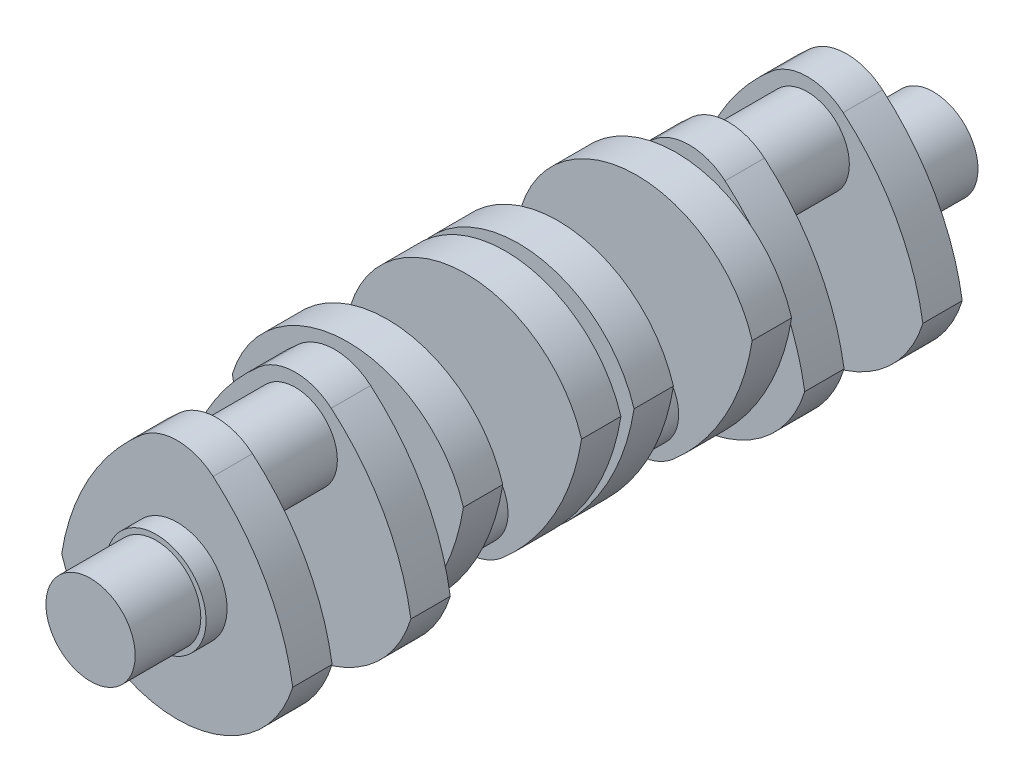
from build123d import *

# Parameters (mm, degrees)
SKETCH1_R           = 17
BOSS_EXTRUDE1_DEPTH = 25
SKETCH2_R           = 19
BOSS_EXTRUDE2_DEPTH = 8
BOSS_EXTRUDE3_DEPTH = 15
SKETCH4_R           = 16
BOSS_EXTRUDE4_DEPTH = 15
SKETCH5_R           = 17
BOSS_EXTRUDE5_DEPTH = 5
BOSS_EXTRUDE6_DEPTH = 15
SKETCH7_R           = 16
BOSS_EXTRUDE7_DEPTH = 30
BOSS_EXTRUDE8_DEPTH = 15
SKETCH9_R           = 17
BOSS_EXTRUDE9_DEPTH = 2.5


with BuildPart() as part:
    # Sketch1 → Boss-Extrude1 (new body)
    with BuildSketch(Plane.XY):
        Circle(SKETCH1_R)
    extrude(amount=BOSS_EXTRUDE1_DEPTH)

    # Sketch2 → Boss-Extrude2 (add)
    with BuildSketch(Plane(origin=(0, 0, 0), x_dir=(-1, 0, 0), z_dir=(0, 0, -1))):
        Circle(SKETCH2_R)
    extrude(amount=BOSS_EXTRUDE2_DEPTH)

    # Sketch3 → Boss-Extrude3 (add)
    with BuildSketch(Plane(origin=(0, 0, -8), x_dir=(-1, 0, 0), z_dir=(0, 0, -1))):
        with BuildLine():
            ThreePointArc((-44, -13.416407865), (0, -46), (44, -13.416407865))
            ThreePointArc((44, -13.416407865), (33.683444249, 16.469257624), (13.668094758, 40.943123461))
            ThreePointArc((13.668094758, 40.943123461), (0, 46), (-13.668094758, 40.943123461))
            ThreePointArc((-13.668094758, 40.943123461), (-33.683444249, 16.469257624), (-44, -13.416407865))
        make_face()
    boss_extrude3 = extrude(amount=BOSS_EXTRUDE3_DEPTH)

    # Sketch4 → Boss-Extrude4 (add)
    with BuildSketch(Plane(origin=(0, 0, -23), x_dir=(-1, 0, 0), z_dir=(0, 0, -1))):
        with Locations((0, 25)):
            Circle(SKETCH4_R)
    boss_extrude4 = extrude(amount=BOSS_EXTRUDE4_DEPTH)

    # Mirror2: Boss-Extrude3, Boss-Extrude4 across plane
    add(boss_extrude3.mirror(Plane(origin=(0, 25, -38), x_dir=(1, 0, 0), z_dir=(0, 0, -1))))
    add(boss_extrude4.mirror(Plane(origin=(0, 25, -38), x_dir=(1, 0, 0), z_dir=(0, 0, -1))))

    # Sketch5 → Boss-Extrude5 (add)
    with BuildSketch(Plane(origin=(0, 0, -68), x_dir=(-1, 0, 0), z_dir=(0, 0, -1))):
        Circle(SKETCH5_R)
    extrude(amount=BOSS_EXTRUDE5_DEPTH)

    # Sketch6 → Boss-Extrude6 (add)
    with BuildSketch(Plane(origin=(0, 0, -73), x_dir=(-1, 0, 0), z_dir=(0, 0, -1))):
        with BuildLine():
            ThreePointArc((44, 13.416407865), (0, 46), (-44, 13.416407865))
            ThreePointArc((-44, 13.416407865), (-33.683444249, -16.469257624), (-13.668094758, -40.943123461))
            ThreePointArc((-13.668094758, -40.943123461), (0, -46), (13.668094758, -40.943123461))
            ThreePointArc((13.668094758, -40.943123461), (33.683444249, -16.469257624), (44, 13.416407865))
        make_face()
    extrude(amount=BOSS_EXTRUDE6_DEPTH)

    # Sketch7 → Boss-Extrude7 (add)
    with BuildSketch(Plane(origin=(0, 0, -88), x_dir=(-1, 0, 0), z_dir=(0, 0, -1))):
        with Locations((0, -25)):
            Circle(SKETCH7_R)
    extrude(amount=BOSS_EXTRUDE7_DEPTH)

    # Sketch8 → Boss-Extrude8 (add)
    with BuildSketch(Plane(origin=(0, 0, -118), x_dir=(-1, 0, 0), z_dir=(0, 0, -1))):
        with BuildLine():
            ThreePointArc((44, 13.416407865), (0, 46), (-44, 13.416407865))
            ThreePointArc((-44, 13.416407865), (-33.683444249, -16.469257624), (-13.668094758, -40.943123461))
            ThreePointArc((-13.668094758, -40.943123461), (0, -46), (13.668094758, -40.943123461))
            ThreePointArc((13.668094758, -40.943123461), (33.683444249, -16.469257624), (44, 13.416407865))
        make_face()
    extrude(amount=BOSS_EXTRUDE8_DEPTH)

    # Sketch9 → Boss-Extrude9 (add)
    with BuildSketch(Plane(origin=(0, 0, -133), x_dir=(-1, 0, 0), z_dir=(0, 0, -1))):
        Circle(SKETCH9_R)
    extrude(amount=BOSS_EXTRUDE9_DEPTH)

    # Mirror3: part across plane


with BuildPart() as part_1:
    add(part.part)
    add(part.part.mirror(Plane(origin=(0, 0, -135.5), x_dir=(1, 0, 0), z_dir=(0, 0, -1))))


solid = part_1.part
